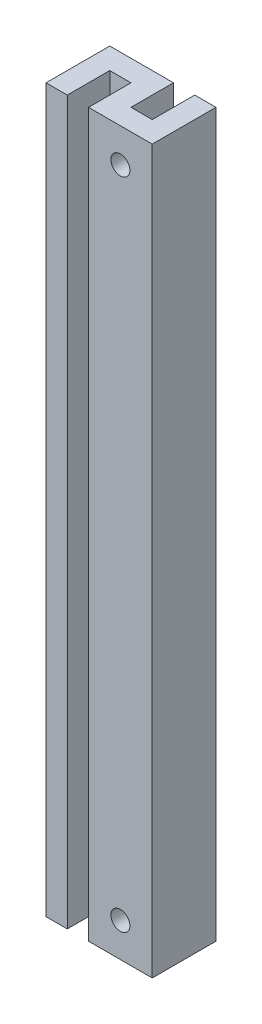
from build123d import *

# Parameters (mm, degrees)
EXTRUDE1_DEPTH                  = 53.975
SKETCH2_R                       = 1.1303
EXTRUDE2_DEPTH                  = 10.525
EXTRUDE3_REACH                  = 11.525
SKETCH3_R                       = 1.1303
F_4_40_TAPPED_HOLE1_D           = 2.2606
F_4_40_TAPPED_HOLE1_DEPTH       = 8.89
F_4_40_TAPPED_HOLE1_CBORE_D     = 2.8448
F_4_40_TAPPED_HOLE1_CBORE_DEPTH = 5.588
F_4_40_TAPPED_HOLE1_TIP         = 0.679152758


with BuildPart() as part:
    # Sketch1 → Extrude1 (new body, symmetric)
    with BuildSketch(Plane(origin=(0, 0, 0), x_dir=(1, 0, 0), z_dir=(0, 1, 0))):
        Polygon((-1.5875, -4.7625), (7.9375, -4.7625), (7.9375, 4.7625), (4.7625, 4.7625), (4.7625, -1.5875), (1.5875, -1.5875), (1.5875, 4.7625), (-7.9375, 4.7625), (-7.9375, -4.7625), (-4.7625, -4.7625), (-4.7625, 1.5875), (-1.5875, 1.5875), align=None)
    extrude(amount=EXTRUDE1_DEPTH, both=True)

    # Sketch2 → Extrude2 (cut, through all)
    with BuildSketch(Plane.XY.offset(4.7625)):
        with Locations((3.175, -48.895)):
            Circle(SKETCH2_R)
        with Locations((3.175, 48.895)):
            Circle(SKETCH2_R)
    extrude(amount=-EXTRUDE2_DEPTH, mode=Mode.SUBTRACT)

    # Sketch3 → Extrude3 (cut, up to next)
    with BuildSketch(Plane(origin=(0, 0, -4.7625), x_dir=(-1, 0, 0), z_dir=(0, 0, -1)), mode=Mode.PRIVATE) as extrude3_sk1:
        with Locations((3.175, 49.2125)):
            Circle(SKETCH3_R)
    extrude3_tool1 = extrude(extrude3_sk1.sketch, amount=-EXTRUDE3_REACH, mode=Mode.PRIVATE) & part.part
    add(extrude3_tool1.solids().sort_by_distance((-3.175, 49.2125, -4.7625))[0], mode=Mode.SUBTRACT)

    # #4-40 Tapped Hole1
    with Locations(Plane(origin=(3.175, 48.895, 4.7625), x_dir=(1, 0, 0), z_dir=(0, 0, 1))):
        with Locations((0, 0), (0, -97.79)):
            CounterBoreHole(F_4_40_TAPPED_HOLE1_D / 2, F_4_40_TAPPED_HOLE1_CBORE_D / 2, F_4_40_TAPPED_HOLE1_CBORE_DEPTH, depth=F_4_40_TAPPED_HOLE1_DEPTH)
            with Locations((0, 0, -(F_4_40_TAPPED_HOLE1_DEPTH + F_4_40_TAPPED_HOLE1_TIP / 2))):  # 118° drill point
                Cone(0, F_4_40_TAPPED_HOLE1_D / 2, F_4_40_TAPPED_HOLE1_TIP, mode=Mode.SUBTRACT)


solid = part.part
